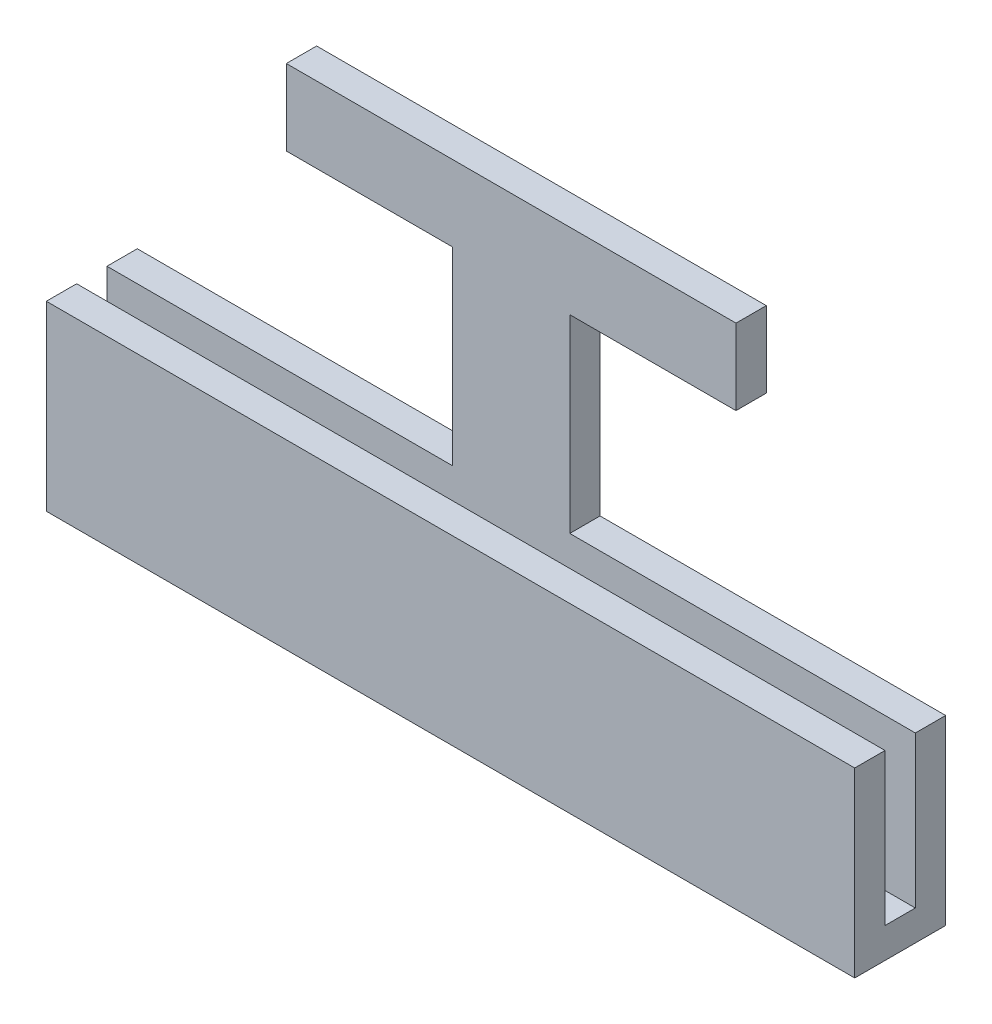
from build123d import *

# Parameters (mm, degrees)
SKETCH1_W           = 80
SKETCH1_H           = 15
BOSS_EXTRUDE1_DEPTH = 3
BOSS_EXTRUDE2_DEPTH = 3
SKETCH2_W           = 80
SKETCH2_H           = 3
BOSS_EXTRUDE3_DEPTH = 3


with BuildPart() as part:
    # Sketch1 → Boss-Extrude1 (new body)
    with BuildSketch(Plane.XY):
        Rectangle(SKETCH1_W, SKETCH1_H)
    extrude(amount=BOSS_EXTRUDE1_DEPTH)



with BuildPart() as body_2:
    # Sketch3 → Boss-Extrude2 (new body)
    with BuildSketch(Plane(origin=(0, 0, -3), x_dir=(-1, 0, 0), z_dir=(0, 0, -1))):
        Polygon((40, -7.5), (-40, -7.5), (-40, 7.5), (-5.8, 7.5), (-5.8, 26.25), (-22.25, 26.25), (-22.25, 33.75), (22.25, 33.75), (22.25, 26.25), (5.8, 26.25), (5.8, 7.5), (40, 7.5), align=None)
    extrude(amount=BOSS_EXTRUDE2_DEPTH)


with BuildPart() as part_1:
    add(part.part)

    add(body_2.part)  # Boss-Extrude3 merges body 2
    # Sketch2 → Boss-Extrude3 (add)
    with BuildSketch(Plane(origin=(0, -7.5, 0), x_dir=(1, 0, 0), z_dir=(0, 1, 0))):
        with Locations((0, 4.5)):
            Rectangle(SKETCH2_W, SKETCH2_H)
        with Locations((0, 1.5)):
            Rectangle(SKETCH2_W, SKETCH2_H)
        with Locations((0, -1.5)):
            Rectangle(SKETCH2_W, SKETCH2_H)
    extrude(amount=-BOSS_EXTRUDE3_DEPTH)


solid = part_1.part
